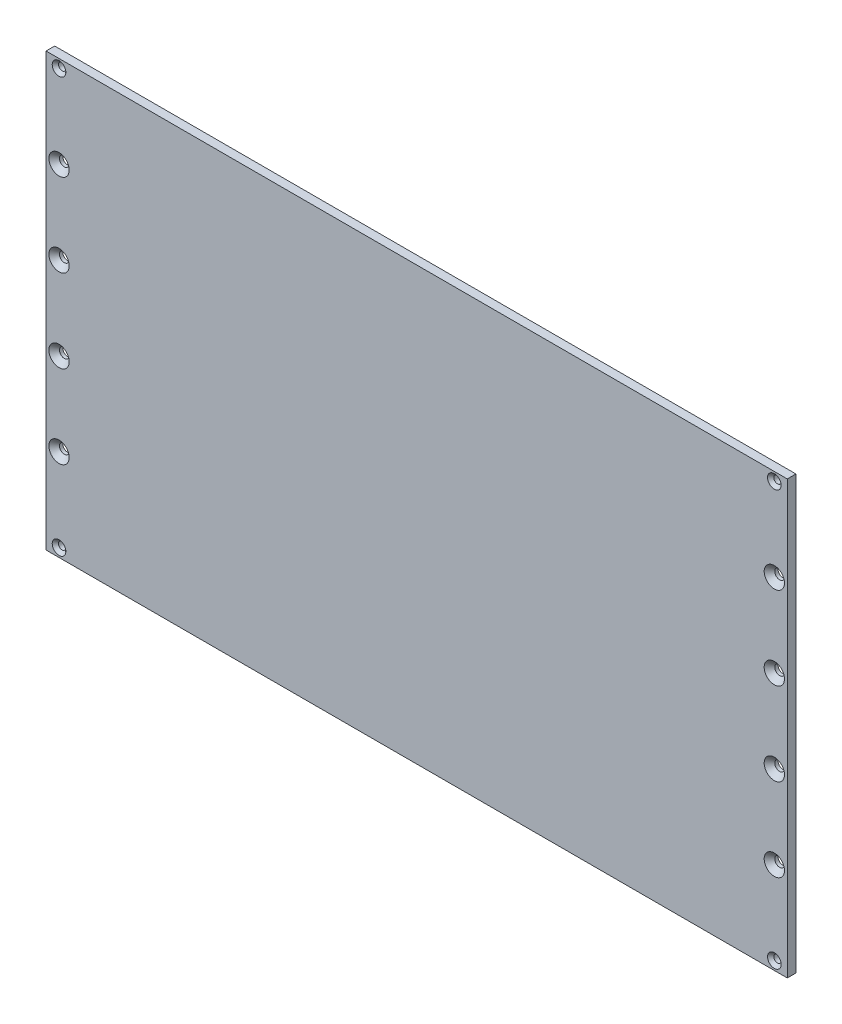
from build123d import *

# Parameters (mm, degrees)
SKETCH1_W                                           = 343
SKETCH1_H                                           = 200
EXTRUDE1_DEPTH                                      = 4
CSK_FOR_M3_COUNTERSUNK_FLAT_HEAD_SCREW1_D           = 3.4
CSK_FOR_M3_COUNTERSUNK_FLAT_HEAD_SCREW1_CSINK_D     = 6.3
CSK_FOR_M3_COUNTERSUNK_FLAT_HEAD_SCREW1_CSINK_ANGLE = 90
CSK_FOR_M4_COUNTERSUNK_FLAT_HEAD_SCR_2_COUNT        = 2
CSK_FOR_M4_COUNTERSUNK_FLAT_HEAD_SCR_2_PITCH        = 331
LPATTERN1_COUNT                                     = 4
LPATTERN1_PITCH                                     = 38.4


with BuildPart() as part:
    # Sketch1 → Extrude1 (new body)
    with BuildSketch(Plane.XY):
        with Locations((171.5, 100)):
            Rectangle(SKETCH1_W, SKETCH1_H)
    extrude(amount=EXTRUDE1_DEPTH)

    # CSK for M3 Countersunk Flat Head Screw1 (through all)
    with Locations(Plane(origin=(6, 196, 4), x_dir=(1, 0, 0), z_dir=(0, 0, 1))):
        with Locations((0, 0), (0, -192), (331, -192), (331, 0)):
            CounterSinkHole(CSK_FOR_M3_COUNTERSUNK_FLAT_HEAD_SCREW1_D / 2, CSK_FOR_M3_COUNTERSUNK_FLAT_HEAD_SCREW1_CSINK_D / 2, counter_sink_angle=CSK_FOR_M3_COUNTERSUNK_FLAT_HEAD_SCREW1_CSINK_ANGLE)

    # Sketch4 → CSK for M4 Countersunk Flat Head Screw1 (revolve, cut)
    with BuildSketch(Plane(origin=(6, 42.4, 4), x_dir=(0, -1, 0), z_dir=(1, 0, 0))):
        Polygon((0, 0), (0, 4), (2.25, 4), (2.25, 2.45), (4.7, 0), align=None)
    csk_for_m4_countersunk_flat_head_screw1 = revolve(axis=Axis((6, 42.4, 10.35), (0, 0, -1)), mode=Mode.SUBTRACT)

    # CSK for M4 Countersunk Flat Head Scr 2: CSK for M4 Countersunk Flat Head Screw1 ×2
    with Locations(*[(i * CSK_FOR_M4_COUNTERSUNK_FLAT_HEAD_SCR_2_PITCH, 0, 0) for i in range(1, CSK_FOR_M4_COUNTERSUNK_FLAT_HEAD_SCR_2_COUNT)]):
        add(csk_for_m4_countersunk_flat_head_screw1, mode=Mode.SUBTRACT)

    # LPattern1: CSK for M4 Countersunk Flat Head Screw1 ×4
    with Locations(*[(0, i * LPATTERN1_PITCH, 0) for i in range(1, LPATTERN1_COUNT)]):
        add(csk_for_m4_countersunk_flat_head_screw1, mode=Mode.SUBTRACT)

    # LPattern1 copy 1 sketch → LPattern1 copy 1 (revolve, cut)
    with BuildSketch(Plane(origin=(337, 80.8, 4), x_dir=(0, -1, 0), z_dir=(1, 0, 0))):
        Polygon((0, 0), (0, 4), (2.25, 4), (2.25, 2.45), (4.7, 0), align=None)
    revolve(axis=Axis((337, 80.8, 10.35), (0, 0, -1)), mode=Mode.SUBTRACT)

    # LPattern1 copy 2 sketch → LPattern1 copy 2 (revolve, cut)
    with BuildSketch(Plane(origin=(337, 119.2, 4), x_dir=(0, -1, 0), z_dir=(1, 0, 0))):
        Polygon((0, 0), (0, 4), (2.25, 4), (2.25, 2.45), (4.7, 0), align=None)
    revolve(axis=Axis((337, 119.2, 10.35), (0, 0, -1)), mode=Mode.SUBTRACT)

    # LPattern1 copy 3 sketch → LPattern1 copy 3 (revolve, cut)
    with BuildSketch(Plane(origin=(337, 157.6, 4), x_dir=(0, -1, 0), z_dir=(1, 0, 0))):
        Polygon((0, 0), (0, 4), (2.25, 4), (2.25, 2.45), (4.7, 0), align=None)
    revolve(axis=Axis((337, 157.6, 10.35), (0, 0, -1)), mode=Mode.SUBTRACT)


solid = part.part
